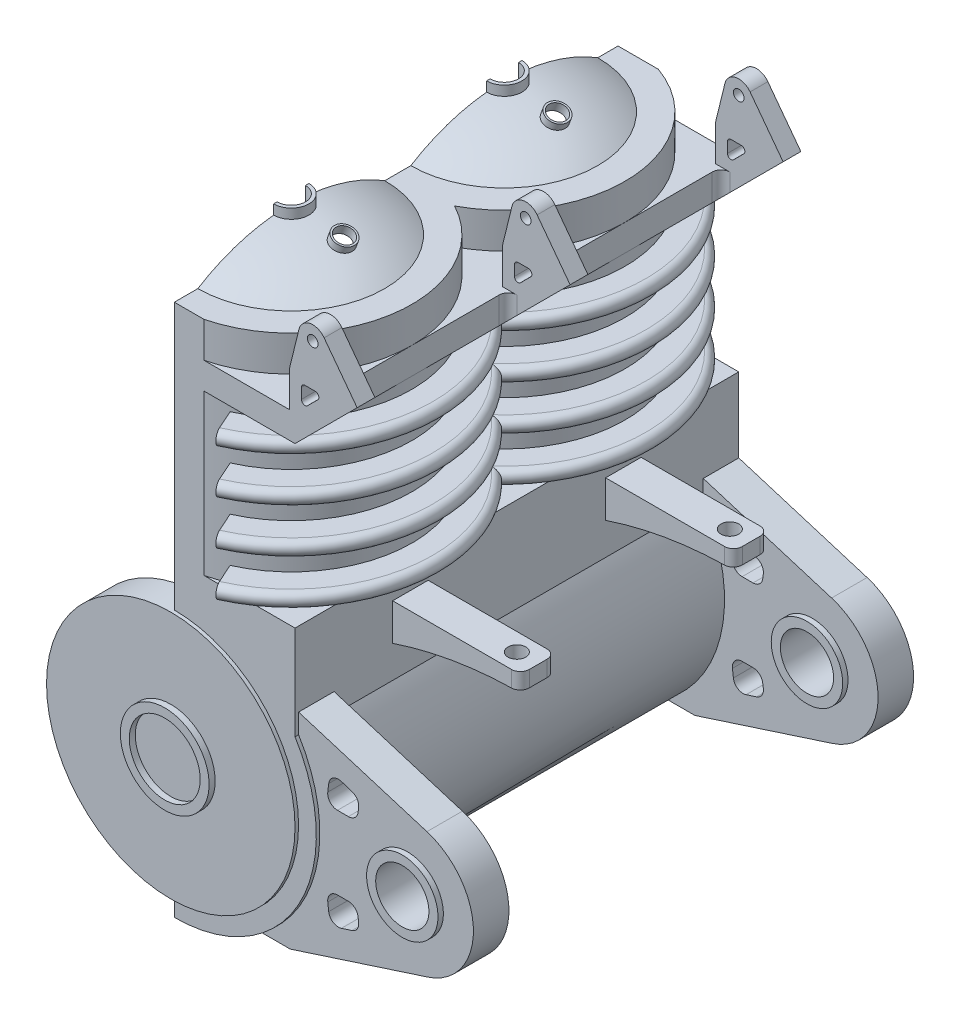
from build123d import *

# Parameters (mm, degrees)
BOSS_EXTRUDE1_DEPTH  = 25
SKETCH2_R            = 5
CUT_EXTRUDE1_DEPTH   = 20
SKETCH5_R            = 7
CUT_EXTRUDE2_DEPTH   = 26
CUT_EXTRUDE3_DEPTH   = 9
SKETCH7_W            = 0.505
SKETCH7_H            = 10
REVOLVE1_ANGLE       = 156
LPATTERN1_COUNT      = 2
LPATTERN1_PITCH      = 12
SKETCH9_R            = 5
CUT_EXTRUDE4_DEPTH   = 16.62
BOSS_EXTRUDE2_START  = -1
SKETCH10_R           = 7
SKETCH10_R_2         = 2.5
BOSS_EXTRUDE2_DEPTH  = 1.5
LPATTERN2_COUNT      = 3
LPATTERN2_PITCH      = 12
BOSS_EXTRUDE3_DEPTH  = 0.2
BOSS_EXTRUDE4_START  = -1.6
SKETCH12_R           = 2.5
SKETCH12_R_2         = 2
BOSS_EXTRUDE4_DEPTH  = 2.1
LPATTERN3_COUNT      = 3
LPATTERN3_PITCH      = 12.22
BOSS_EXTRUDE5_DEPTH  = 2
SKETCH15_R           = 2.013
BOSS_EXTRUDE7_DEPTH  = 2
LPATTERN4_COUNT      = 2
LPATTERN4_PITCH      = 22.8
BOSS_EXTRUDE8_START  = -2.3
SKETCH16_R           = 2.013
SKETCH16_R_2         = 1.5
BOSS_EXTRUDE8_DEPTH  = 2.6
LPATTERN5_COUNT      = 2
LPATTERN5_PITCH      = 22.8
CUT_EXTRUDE5_DEPTH   = 27.070078762
REVOLVE2_ANGLE       = 180
LPATTERN6_COUNT      = 2
LPATTERN6_PITCH      = 12
SKETCH19_R           = 0.995
CUT_EXTRUDE6_DEPTH   = 10
BOSS_EXTRUDE9_START  = 1.2
BOSS_EXTRUDE9_DEPTH  = 0.8
SKETCH22_R           = 0.6
CUT_EXTRUDE7_DEPTH   = 8.574362742
SKETCH23_R           = 0.3
SKETCH23_W           = 0.315
SKETCH23_H           = 1.500000048
BOSS_EXTRUDE10_DEPTH = 1
LPATTERN7_COUNT      = 3
LPATTERN7_PITCH      = 12
FILLET1_R            = 0.5
BOSS_EXTRUDE11_START = -5.5
BOSS_EXTRUDE11_DEPTH = 2
LPATTERN8_COUNT      = 2
LPATTERN8_PITCH      = 12
SKETCH25_R           = 0.5
CUT_EXTRUDE8_DEPTH   = 2
FILLET2_R            = 0.5
SKETCH26_W           = 5.684070648
SKETCH26_H           = 1.958270425
CUT_EXTRUDE9_DEPTH   = 27.070078762
SKETCH27_R           = 0.3
BOSS_EXTRUDE12_DEPTH = 1
LPATTERN9_COUNT      = 3
LPATTERN9_PITCH      = 12
EXTRUDE_THIN1_START  = 1.9
SKETCH22_2_R         = 0.6
SKETCH22_2_R_2       = 0.5
EXTRUDE_THIN1_DEPTH  = 0.5


with BuildPart() as part:
    # Sketch1 → Boss-Extrude1 (new body)
    with BuildSketch(Plane.XY):
        with BuildLine():
            Line((6.8, 28.02), (0, 28.02))
            Line((0, 28.02), (0, 0))
            ThreePointArc((0, 0), (6.989781542, 4.108605135), (6.8, 12.214261501))
            Line((6.8, 12.214261501), (6.8, 28.02))
        make_face()
    extrude(amount=BOSS_EXTRUDE1_DEPTH)

    # Sketch2 → Cut-Extrude1 (cut)
    with BuildSketch(Plane(origin=(0, 28.02, 0), x_dir=(1, 0, 0), z_dir=(0, 1, 0))):
        with Locations((0, -18.41)):
            Circle(SKETCH2_R)
        with Locations((0, -6.41)):
            Circle(SKETCH2_R)
    extrude(amount=-CUT_EXTRUDE1_DEPTH, mode=Mode.SUBTRACT)

    # Sketch5 → Cut-Extrude2 (cut, through all)
    with BuildSketch(Plane.XY.offset(25)):
        with Locations((0, 8)):
            Circle(SKETCH5_R)
    extrude(amount=-CUT_EXTRUDE2_DEPTH, mode=Mode.SUBTRACT)

    # Sketch6 → Cut-Extrude3 (cut)
    with BuildSketch(Plane(origin=(0, 26.519999952, 0), x_dir=(1, 0, 0), z_dir=(0, 1, 0))):
        with BuildLine():
            Line((0, 0.39), (8.818172163, 0.39))
            Line((8.818172163, 0.39), (8.818172163, -25.21))
            Line((8.818172163, -25.21), (0, -25.21))
            ThreePointArc((0, -25.21), (6.596969001, -20.05924225), (3.2, -12.41))
            ThreePointArc((3.2, -12.41), (6.596969001, -4.76075775), (0, 0.39))
        make_face()
    extrude(amount=-CUT_EXTRUDE3_DEPTH, mode=Mode.SUBTRACT)

    # Sketch7 → Revolve1 (revolve)
    with BuildSketch(Plane.ZY):
        with BuildLine():
            Line((0, 25.07), (0, 25.87))
            Line((0, 25.87), (-1.575, 25.87))
            ThreePointArc((-1.575, 25.87), (-1.975, 25.47), (-1.575, 25.07))
            Line((-1.575, 25.07), (0, 25.07))
        make_face()
        with BuildLine():
            Line((0, 22.57), (0, 23.37))
            Line((0, 23.37), (-1.575, 23.37))
            ThreePointArc((-1.575, 23.37), (-1.975, 22.97), (-1.575, 22.57))
            Line((-1.575, 22.57), (0, 22.57))
        make_face()
        with BuildLine():
            Line((0, 20.07), (0, 20.87))
            Line((0, 20.87), (-1.575, 20.87))
            ThreePointArc((-1.575, 20.87), (-1.975, 20.47), (-1.575, 20.07))
            Line((-1.575, 20.07), (0, 20.07))
        make_face()
        with BuildLine():
            Line((-1.575, 17.57), (0, 17.57))
            Line((0, 17.57), (0, 18.37))
            Line((0, 18.37), (-1.575, 18.37))
            ThreePointArc((-1.575, 18.37), (-1.975, 17.97), (-1.575, 17.57))
        make_face()
        with Locations((0.4275, 22.17)):
            Rectangle(SKETCH7_W, SKETCH7_H)
    revolve1 = revolve(axis=Axis((0, 28.02, 6.41), (0, -1, 0)), revolution_arc=REVOLVE1_ANGLE)

    # LPattern1: Revolve1 ×2
    with Locations(*[(0, 0, i * LPATTERN1_PITCH) for i in range(1, LPATTERN1_COUNT)]):
        add(revolve1)

    # Sketch9 → Cut-Extrude4 (cut)
    with BuildSketch(Plane(origin=(0, 28.02, 0), x_dir=(1, 0, 0), z_dir=(0, 1, 0))):
        with Locations((0, -6.41)):
            Circle(SKETCH9_R)
    extrude(amount=-CUT_EXTRUDE4_DEPTH, mode=Mode.SUBTRACT)

    # Sketch10 → Boss-Extrude2 (add)
    with BuildSketch(Plane(origin=(0, 0, 0), x_dir=(-1, 0, 0), z_dir=(0, 0, -1)).offset(BOSS_EXTRUDE2_START)):
        with Locations((0, 8)):
            Circle(SKETCH10_R)
        with Locations((0, 8)):
            Circle(SKETCH10_R_2, mode=Mode.SUBTRACT)
    boss_extrude2 = extrude(amount=BOSS_EXTRUDE2_DEPTH)

    # LPattern2: Boss-Extrude2 ×3
    with Locations(*[(0, 0, i * LPATTERN2_PITCH) for i in range(1, LPATTERN2_COUNT)]):
        add(boss_extrude2)

    # Sketch11 → Boss-Extrude3 (add)
    with BuildSketch(Plane.XY.offset(25)):
        with BuildLine():
            ThreePointArc((0, 1), (7, 8), (0, 15))
            ThreePointArc((0, 15), (-7, 8), (0, 1))
        make_face()
    extrude(amount=BOSS_EXTRUDE3_DEPTH)

    # Sketch12 → Boss-Extrude4 (add)
    with BuildSketch(Plane(origin=(0, 0, -0.5), x_dir=(-1, 0, 0), z_dir=(0, 0, -1)).offset(BOSS_EXTRUDE4_START)):
        with Locations((0, 8)):
            Circle(SKETCH12_R)
        with Locations((0, 8)):
            Circle(SKETCH12_R_2, mode=Mode.SUBTRACT)
    boss_extrude4 = extrude(amount=BOSS_EXTRUDE4_DEPTH)

    # LPattern3: Boss-Extrude4 ×3
    with Locations(*[(0, 0, i * LPATTERN3_PITCH) for i in range(1, LPATTERN3_COUNT)]):
        add(boss_extrude4)

    # Sketch13 → Boss-Extrude5 (add)
    with BuildSketch(Plane(origin=(0, 28.02, 0), x_dir=(1, 0, 0), z_dir=(0, 1, 0))):
        with BuildLine():
            ThreePointArc((6.8, -6.41), (5.553129844, -2.485366395), (2.269779725, 0))
            Line((2.269779725, 0), (0, 0))
            Line((0, 0), (0, -1.41))
            ThreePointArc((0, -1.41), (5, -6.41), (0, -11.41))
            Line((0, -11.41), (0, -13.41))
            ThreePointArc((0, -13.41), (5, -18.41), (0, -23.41))
            Line((0, -23.41), (0, -25))
            Line((0, -25), (1.676872088, -25))
            ThreePointArc((1.676872088, -25), (5.368553353, -22.583563813), (6.8, -18.41))
            ThreePointArc((6.8, -18.41), (5.830951895, -14.911428863), (3.2, -12.41))
            ThreePointArc((3.2, -12.41), (5.830951895, -9.908571137), (6.8, -6.41))
        make_face()
    extrude(amount=BOSS_EXTRUDE5_DEPTH)

    # Sketch15 → Boss-Extrude7 (add)
    with BuildSketch(Plane(origin=(0, 0, 0), x_dir=(-1, 0, 0), z_dir=(0, 0, -1))):
        with BuildLine():
            Line((-6.8, 13.320326032), (-14.031424442, 11.101418324))
            ThreePointArc((-14.031424442, 11.101418324), (-16.650997852, 7.561491091), (-14.039052939, 4.015931412))
            Line((-14.039052939, 4.015931412), (-6.329842019, 1.519716796))
            Line((-6.329842019, 1.519716796), (-4.691047814, 1.519716796))
            ThreePointArc((-4.691047814, 1.519716796), (-7.84884492, 6.45221661), (-6.8, 12.214261501))
            Line((-6.8, 12.214261501), (-6.8, 13.320326032))
        make_face()
        with Locations((-12.944, 7.5575)):
            Circle(SKETCH15_R, mode=Mode.SUBTRACT)
    boss_extrude7 = extrude(amount=-BOSS_EXTRUDE7_DEPTH)

    # LPattern4: Boss-Extrude7 ×2
    with Locations(*[(0, 0, i * LPATTERN4_PITCH) for i in range(1, LPATTERN4_COUNT)]):
        add(boss_extrude7)

    # Sketch16 → Boss-Extrude8 (add)
    with BuildSketch(Plane(origin=(0, 0, 0), x_dir=(-1, 0, 0), z_dir=(0, 0, -1)).offset(BOSS_EXTRUDE8_START)):
        with Locations((-12.944, 7.5575)):
            Circle(SKETCH16_R)
        with Locations((-12.944, 7.5575)):
            Circle(SKETCH16_R_2, mode=Mode.SUBTRACT)
    boss_extrude8 = extrude(amount=BOSS_EXTRUDE8_DEPTH)

    # LPattern5: Boss-Extrude8 ×2
    with Locations(*[(0, 0, i * LPATTERN5_PITCH) for i in range(1, LPATTERN5_COUNT)]):
        add(boss_extrude8)

    # Sketch17 → Cut-Extrude5 (cut, through all)
    with BuildSketch(Plane(origin=(0, 0, 0), x_dir=(-1, 0, 0), z_dir=(0, 0, -1))):
        with BuildLine():
            ThreePointArc((-10.150487491, 5.017597963), (-9.966742066, 5.356336211), (-9.605799531, 5.491341649))
            Line((-9.605799531, 5.491341649), (-8.99147292, 5.491341649))
            ThreePointArc((-8.99147292, 5.491341649), (-8.58017978, 5.306496347), (-8.445343385, 4.876206934))
            Line((-8.445343385, 4.876206934), (-8.498134995, 4.433569584))
            ThreePointArc((-8.498134995, 4.433569584), (-8.747072593, 4.03591174), (-9.212249685, 3.974985875))
            Line((-9.212249685, 3.974985875), (-9.808958319, 4.166382984))
            ThreePointArc((-9.808958319, 4.166382984), (-10.10677158, 4.397643145), (-10.185661125, 4.766357723))
            Line((-10.185661125, 4.766357723), (-10.150487491, 5.017597963))
        make_face()
        with BuildLine():
            Line((-9.212249685, 11.140014125), (-9.808958319, 10.948617016))
            ThreePointArc((-9.808958319, 10.948617016), (-10.10677158, 10.717356855), (-10.185661125, 10.348642277))
            Line((-10.185661125, 10.348642277), (-10.150487491, 10.097402037))
            ThreePointArc((-10.150487491, 10.097402037), (-9.966742066, 9.758663789), (-9.605799531, 9.623658351))
            Line((-9.605799531, 9.623658351), (-8.99147292, 9.623658351))
            ThreePointArc((-8.99147292, 9.623658351), (-8.58017978, 9.808503653), (-8.445343385, 10.238793066))
            Line((-8.445343385, 10.238793066), (-8.498134995, 10.681430416))
            ThreePointArc((-8.498134995, 10.681430416), (-8.747072593, 11.07908826), (-9.212249685, 11.140014125))
        make_face()
    extrude(amount=-CUT_EXTRUDE5_DEPTH, mode=Mode.SUBTRACT)

    # Sketch18 → Revolve2 (revolve)
    with BuildSketch(Plane.ZY):
        with BuildLine():
            Line((13.142173124, 30.02), (13.373735852, 30.02))
            ThreePointArc((13.373735852, 30.02), (15.799023171, 31.048756477), (18.41, 31.4))
            Line((18.41, 31.4), (18.41, 31.52))
            ThreePointArc((18.41, 31.52), (15.671387212, 31.137692031), (13.142173124, 30.02))
        make_face()
    revolve2 = revolve(axis=Axis((0, 30.02, 18.41), (0, -1, 0)), revolution_arc=REVOLVE2_ANGLE)

    # LPattern6: Revolve2 ×2
    with Locations(*[(0, 0, -i * LPATTERN6_PITCH) for i in range(1, LPATTERN6_COUNT)]):
        add(revolve2)

    # Sketch19 → Cut-Extrude6 (cut)
    with BuildSketch(Plane(origin=(0, 28.02, 0), x_dir=(1, 0, 0), z_dir=(0, 1, 0))):
        with Locations((0, -6.41)):
            Circle(SKETCH19_R)
        with Locations((0, -18.41)):
            Circle(SKETCH19_R)
    extrude(amount=CUT_EXTRUDE6_DEPTH, mode=Mode.SUBTRACT)

    # Sketch21 → Boss-Extrude9 (add)
    with BuildSketch(Plane(origin=(0, 30.02, 0), x_dir=(1, 0, 0), z_dir=(0, 1, 0)).offset(BOSS_EXTRUDE9_START)):
        with BuildLine():
            Line((0, -5.415), (0, -5.61))
            ThreePointArc((0, -5.61), (0.8, -6.41), (0, -7.21))
            Line((0, -7.21), (0, -7.405))
            ThreePointArc((0, -7.405), (0.995, -6.41), (0, -5.415))
        make_face()
        with BuildLine():
            Line((0, -17.415), (0, -17.61))
            ThreePointArc((0, -17.61), (0.8, -18.41), (0, -19.21))
            Line((0, -19.21), (0, -19.405))
            ThreePointArc((0, -19.405), (0.995, -18.41), (0, -17.415))
        make_face()
    extrude(amount=BOSS_EXTRUDE9_DEPTH)

    # Sketch22 → Cut-Extrude7 (cut, through all)
    with BuildSketch(Plane(origin=(9.648242021, 26.508327091, 0), x_dir=(0, 0, 1), z_dir=(0.342020143, 0.939692621, 0))):
        with Locations((6.41, -7.951484989)):
            Circle(SKETCH22_R)
        with Locations((18.41, -7.951484989)):
            Circle(SKETCH22_R)
    extrude(amount=CUT_EXTRUDE7_DEPTH, mode=Mode.SUBTRACT)

    # Sketch23 → Boss-Extrude10 (add)
    with BuildSketch(Plane(origin=(0, 0, 0), x_dir=(-1, 0, 0), z_dir=(0, 0, -1))):
        with BuildLine():
            Line((-10.715784293, 30.435784245), (-6.8, 26.519999952))
            Line((-6.8, 26.519999952), (-6.8, 28.02))
            Line((-6.8, 28.02), (-6.485, 28.02))
            Line((-6.485, 28.02), (-6.485, 30.02))
            Line((-6.485, 30.02), (-8.805, 30.02))
            Line((-8.805, 30.02), (-9.929299782, 31.144299782))
            ThreePointArc((-9.929299782, 31.144299782), (-10.695756922, 31.204327531), (-10.715784293, 30.435784245))
        make_face()
        with Locations((-10.341017698, 30.810550839)):
            Circle(SKETCH23_R, mode=Mode.SUBTRACT)
        with BuildLine():
            Line((-7.505103511, 28.720103511), (-8.086307128, 29.301307128))
            ThreePointArc((-8.086307128, 29.301307128), (-8.129661678, 29.51926517), (-7.944885771, 29.642728484))
            Line((-7.944885771, 29.642728484), (-7.360259245, 29.642728484))
            ThreePointArc((-7.360259245, 29.642728484), (-7.218422067, 29.583732793), (-7.160262713, 29.441550635))
            Line((-7.160262713, 29.441550635), (-7.163685623, 28.860347018))
            ThreePointArc((-7.163685623, 28.860347018), (-7.287689898, 28.676524389), (-7.505103511, 28.720103511))
        make_face(mode=Mode.SUBTRACT)
        with Locations((-6.6425, 27.269999976)):
            Rectangle(SKETCH23_W, SKETCH23_H)
    boss_extrude10 = extrude(amount=-BOSS_EXTRUDE10_DEPTH)

    # LPattern7: Boss-Extrude10 ×3
    with Locations(*[(0, 0, i * LPATTERN7_PITCH) for i in range(1, LPATTERN7_COUNT)]):
        add(boss_extrude10)

    # Fillet1
    fillet1_edges = [part.edges().sort_by_distance(p)[0] for p in [
        (6.8, 27.269999976, 1),
        (6.8, 27.269999976, 13),
        (6.8, 27.269999976, 12),
        (6.8, 27.269999976, 24),
    ]]
    fillet(fillet1_edges, radius=FILLET1_R)

    # Sketch24 → Boss-Extrude11 (add)
    with BuildSketch(Plane(origin=(0, 0, 0), x_dir=(-1, 0, 0), z_dir=(0, 0, -1)).offset(BOSS_EXTRUDE11_START)):
        with BuildLine():
            Line((-6.8, 16.1), (-14, 16.1))
            Line((-14, 16.1), (-14, 15.2))
            ThreePointArc((-14, 15.2), (-10.352441217, 14.904524284), (-6.8, 14.02580227))
            Line((-6.8, 14.02580227), (-6.8, 16.1))
        make_face()
    boss_extrude11 = extrude(amount=-BOSS_EXTRUDE11_DEPTH)

    # LPattern8: Boss-Extrude11 ×2
    with Locations(*[(0, 0, i * LPATTERN8_PITCH) for i in range(1, LPATTERN8_COUNT)]):
        add(boss_extrude11)

    # Sketch25 → Cut-Extrude8 (cut)
    with BuildSketch(Plane(origin=(0, 16.1, 0), x_dir=(1, 0, 0), z_dir=(0, 1, 0))):
        with Locations((12.8, -6.5)):
            Circle(SKETCH25_R)
        with Locations((12.8, -18.5)):
            Circle(SKETCH25_R)
    extrude(amount=-CUT_EXTRUDE8_DEPTH, mode=Mode.SUBTRACT)

    # Fillet2
    fillet2_edges = [part.edges().sort_by_distance(p)[0] for p in [
        (14, 15.65, 7.5),
        (14, 15.65, 5.5),
        (14, 15.65, 19.5),
        (14, 15.65, 17.5),
    ]]
    fillet(fillet2_edges, radius=FILLET2_R)

    # Sketch26 → Cut-Extrude9 (cut, through all)
    with BuildSketch(Plane(origin=(0, 0, 0), x_dir=(-1, 0, 0), z_dir=(0, 0, -1))):
        with Locations((-9.619117687, 30.999135213)):
            Rectangle(SKETCH26_W, SKETCH26_H)
    extrude(amount=-CUT_EXTRUDE9_DEPTH, mode=Mode.SUBTRACT)

    # Sketch27 → Boss-Extrude12 (add)
    with BuildSketch(Plane(origin=(0, 0, 0), x_dir=(-1, 0, 0), z_dir=(0, 0, -1))):
        with BuildLine():
            Line((-6.485, 30.02), (-7.023090433, 32.21081804))
            ThreePointArc((-7.023090433, 32.21081804), (-7.640023094, 32.803841431), (-8.439999994, 32.500000008))
            Line((-8.439999994, 32.500000008), (-10.300000048, 30.02))
            Line((-10.300000048, 30.02), (-6.485, 30.02))
        make_face()
        with Locations((-7.8, 32.02)):
            Circle(SKETCH27_R, mode=Mode.SUBTRACT)
    boss_extrude12 = extrude(amount=-BOSS_EXTRUDE12_DEPTH)

    # LPattern9: Boss-Extrude12 ×3
    with Locations(*[(0, 0, i * LPATTERN9_PITCH) for i in range(1, LPATTERN9_COUNT)]):
        add(boss_extrude12)

    # Sketch22_2 → Extrude-Thin1 (add)
    with BuildSketch(Plane(origin=(9.648242021, 26.508327091, 0), x_dir=(0, 0, 1), z_dir=(0.342020143, 0.939692621, 0)).offset(EXTRUDE_THIN1_START)):
        with Locations((6.41, -7.951484989)):
            Circle(SKETCH22_2_R)
        with Locations((6.41, -7.951484989)):
            Circle(SKETCH22_2_R_2, mode=Mode.SUBTRACT)
        with Locations((18.41, -7.951484989)):
            Circle(SKETCH22_2_R)
        with Locations((18.41, -7.951484989)):
            Circle(SKETCH22_2_R_2, mode=Mode.SUBTRACT)
    extrude(amount=EXTRUDE_THIN1_DEPTH)


solid = part.part
